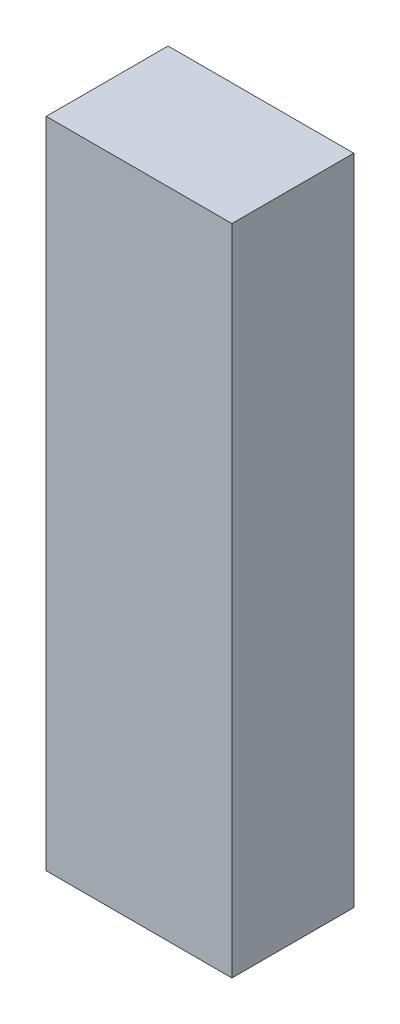
from build123d import *

# Parameters (mm, degrees)
SKETCH2_W           = 168.91
SKETCH2_H           = 48.006
BOSS_EXTRUDE1_DEPTH = 31.496


with BuildPart() as part:
    # Sketch2 → Boss-Extrude1 (new body)
    with BuildSketch(Plane(origin=(0, 0, 0), x_dir=(0, 1, 0), z_dir=(0, 0, 1))):
        Rectangle(SKETCH2_W, SKETCH2_H)
    extrude(amount=BOSS_EXTRUDE1_DEPTH)


solid = part.part
